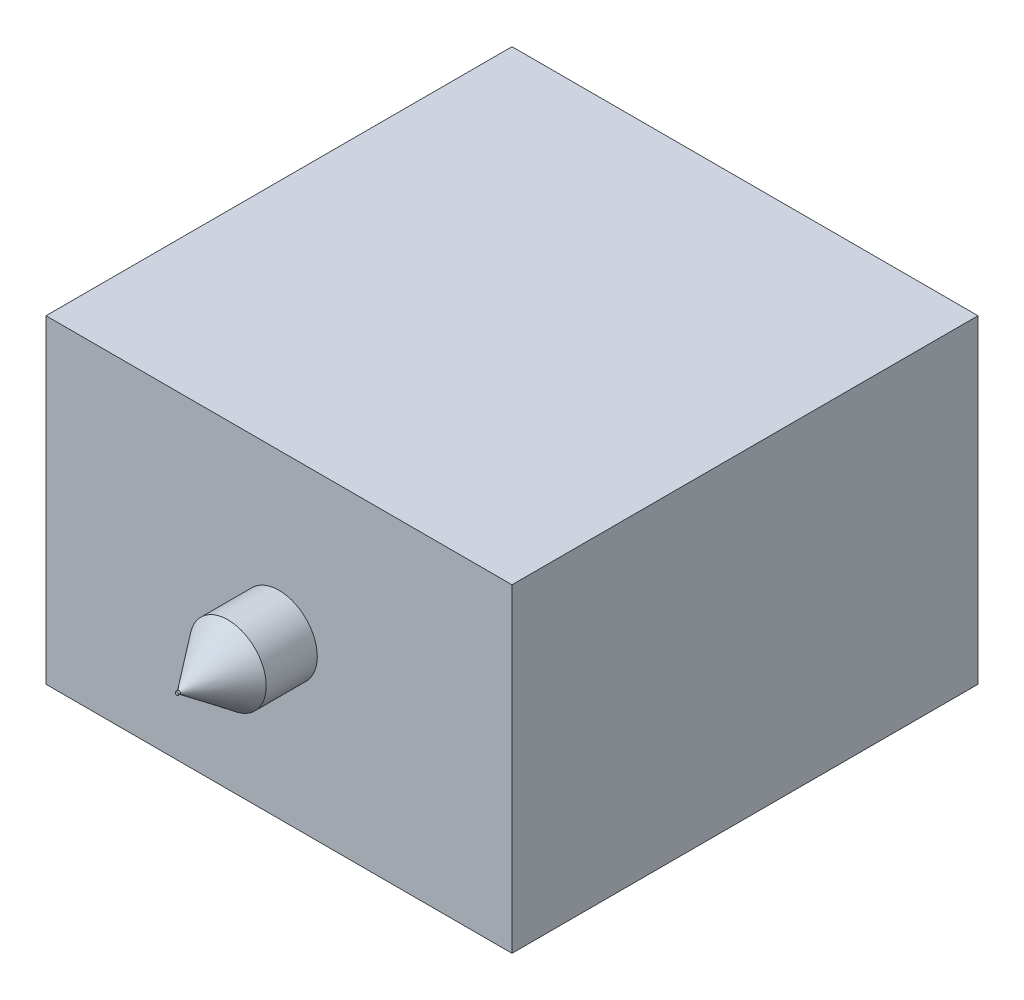
from build123d import *

# Parameters (mm, degrees)
SKETCH1_W           = 457.2
SKETCH1_H           = 304.8
CHAMBER_BASE_DEPTH  = 457.2
SKETCH2_W           = 457.2
SKETCH2_H           = 304.8
BACK_WALL_DEPTH     = 6.35
SKETCH3_W           = 463.55
SKETCH3_H           = 457.2
SIDE_WALL_2_DEPTH   = 6.35
SKETCH5_W           = 463.55
SKETCH5_H           = 457.2
SIDE_WALL_3_DEPTH   = 6.35
SKETCH8_W           = 463.55
SKETCH8_H           = 317.5
TOP_DEPTH           = 6.35
SKETCH9_R           = 38.1
BOSS_EXTRUDE1_DEPTH = 50.8
SKETCH10_R          = 50.8
BOSS_EXTRUDE2_DEPTH = 25.4
SKETCH11_R          = 1.5875
BOSS_EXTRUDE3_DEPTH = 50.8


with BuildPart() as part:
    # Sketch1 → Chamber Base (new body)
    with BuildSketch(Plane.XY):
        with Locations((228.6, 152.4)):
            Rectangle(SKETCH1_W, SKETCH1_H)
    extrude(amount=CHAMBER_BASE_DEPTH)

    # Sketch2 → Back wall (add)
    with BuildSketch(Plane(origin=(457.2, 0, 0), x_dir=(0, 0, -1), z_dir=(1, 0, 0))):
        with Locations((-228.6, 152.4)):
            Rectangle(SKETCH2_W, SKETCH2_H)
    extrude(amount=BACK_WALL_DEPTH)

    # Sketch3 → Side wall 2 (add)
    with BuildSketch(Plane(origin=(0, 304.8, 0), x_dir=(1, 0, 0), z_dir=(0, 1, 0))):
        with Locations((231.775, -228.6)):
            Rectangle(SKETCH3_W, SKETCH3_H)
    extrude(amount=SIDE_WALL_2_DEPTH)

    # Sketch5 → Side wall 3 (add)
    with BuildSketch(Plane.XZ):
        with Locations((231.775, 228.6)):
            Rectangle(SKETCH5_W, SKETCH5_H)
    extrude(amount=SIDE_WALL_3_DEPTH)

    # Sketch8 → Top (add)
    with BuildSketch(Plane.XY.offset(457.2)):
        with Locations((231.775, 152.4)):
            Rectangle(SKETCH8_W, SKETCH8_H)
    extrude(amount=TOP_DEPTH)

    # Sketch9 → Boss-Extrude1 (add)
    with BuildSketch(Plane.XY.offset(463.55)):
        with Locations((231.775, 152.4)):
            Circle(SKETCH9_R)
    extrude(amount=BOSS_EXTRUDE1_DEPTH)

    # Sketch10 → Boss-Extrude2 (add)
    with BuildSketch(Plane(origin=(0, 0, 0), x_dir=(-1, 0, 0), z_dir=(0, 0, -1))):
        with Locations((-231.775, 152.4)):
            Circle(SKETCH10_R)
    extrude(amount=BOSS_EXTRUDE2_DEPTH)

    # Sketch11 → Boss-Extrude3 (add)
    with BuildSketch(Plane.XY.offset(514.35)):
        with Locations((231.775, 152.4)):
            Circle(SKETCH11_R)
    extrude(amount=BOSS_EXTRUDE3_DEPTH)

    # Sketch15 → Revolve1 (revolve)
    with BuildSketch(Plane.ZY.offset(-231.775)):
        Polygon((514.35, 190.5), (514.35, 152.4), (565.15, 152.4), align=None)
    revolve(axis=Axis((231.775, 152.4, 514.35), (0, 0, 1)))


solid = part.part
